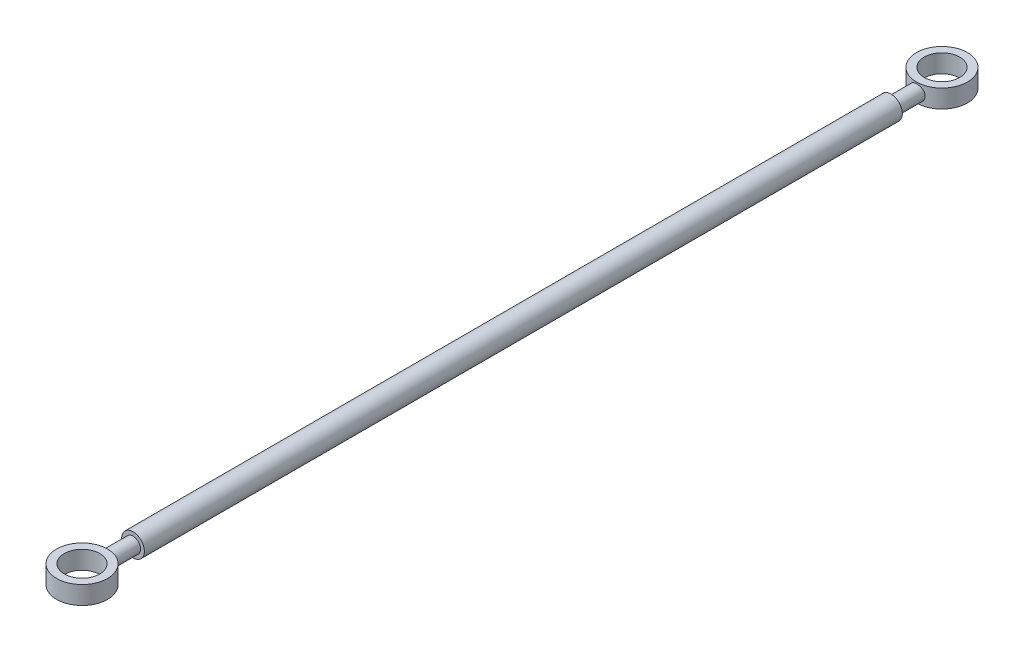
from build123d import *

# Parameters (mm, degrees)
SKETCH_1_R      = 6.725
SKETCH_1_R_2    = 4.68
EXTRUDE_1_DEPTH = 2.4
SKETCH_2_R      = 2
EXTRUDE_2_DEPTH = 107.5
SKETCH_4_R      = 3
EXTRUDE_3_DEPTH = 100


with BuildPart() as part:
    # 스케치1 → 보스-돌출1 (new body, symmetric)
    with BuildSketch(Plane(origin=(0, 0, 0), x_dir=(1, 0, 0), z_dir=(0, 1, 0))):
        Circle(SKETCH_1_R)
        Circle(SKETCH_1_R_2, mode=Mode.SUBTRACT)
    extrude_1 = extrude(amount=EXTRUDE_1_DEPTH, both=True)

    # 스케치2 → 보스-돌출2 (add, symmetric)
    with BuildSketch(Plane.XY.offset(113.45)):
        Circle(SKETCH_2_R)
    extrude(amount=EXTRUDE_2_DEPTH, both=True)

    # 대칭 복사5: 보스-돌출1 across plane
    add(extrude_1.mirror(Plane.XY.offset(113.45)))

    # 스케치4 → 보스-돌출3 (add, symmetric)
    with BuildSketch(Plane.XY.offset(113.45)):
        Circle(SKETCH_4_R)
    extrude(amount=EXTRUDE_3_DEPTH, both=True)


solid = part.part
